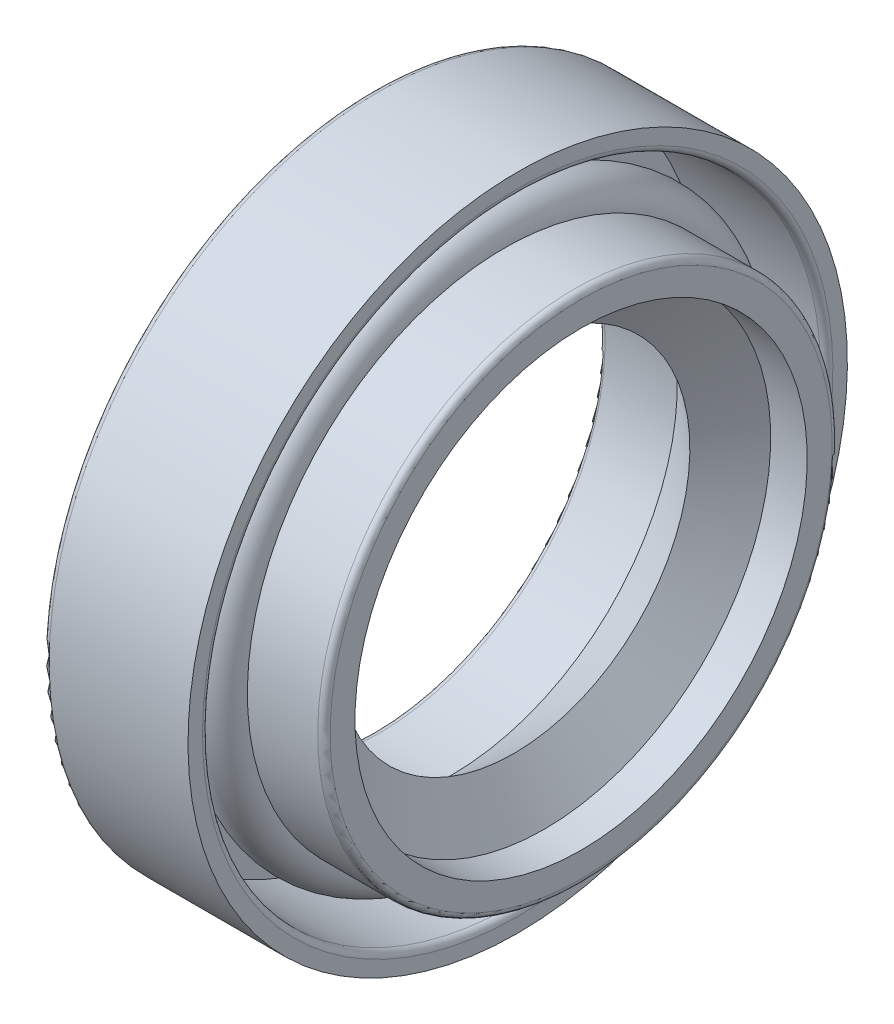
from build123d import *


with BuildPart() as part:
    # Sketch1 → Revolve1 (revolve)
    with BuildSketch(Plane.XY):
        with BuildLine():
            Line((0, 15.614050094), (0, 11.214050094))
            ThreePointArc((0, 11.214050094), (0.087867966, 11.00191806), (0.3, 10.914050094))
            Line((0.3, 10.914050094), (3.793517987, 10.914050094))
            Line((3.793517987, 10.914050094), (6.811080605, 8.5))
            Line((6.811080605, 8.5), (8.296649893, 10.914050094))
            Line((8.296649893, 10.914050094), (10.060763424, 10.914050094))
            Line((10.060763424, 10.914050094), (10.060763424, 12.114050094))
            ThreePointArc((10.060763424, 12.114050094), (9.972895458, 12.326182128), (9.760763424, 12.414050094))
            Line((9.760763424, 12.414050094), (6.36550709, 12.414050094))
            ThreePointArc((6.36550709, 12.414050094), (5.079512539, 13.700044645), (3.793517987, 12.414050094))
            Line((3.793517987, 12.414050094), (1, 12.414050094))
            Line((1, 12.414050094), (1, 14.914050094))
            Line((1, 14.914050094), (6.7, 14.914050094))
            ThreePointArc((6.7, 14.914050094), (6.912132034, 15.00191806), (7, 15.214050094))
            Line((7, 15.214050094), (7, 15.914050094))
            Line((7, 15.914050094), (0.3, 15.914050094))
            ThreePointArc((0.3, 15.914050094), (0.087867966, 15.826182128), (0, 15.614050094))
        make_face()
    revolve(axis=Axis((0, 0, 0), (1, 0, 0)))


solid = part.part
